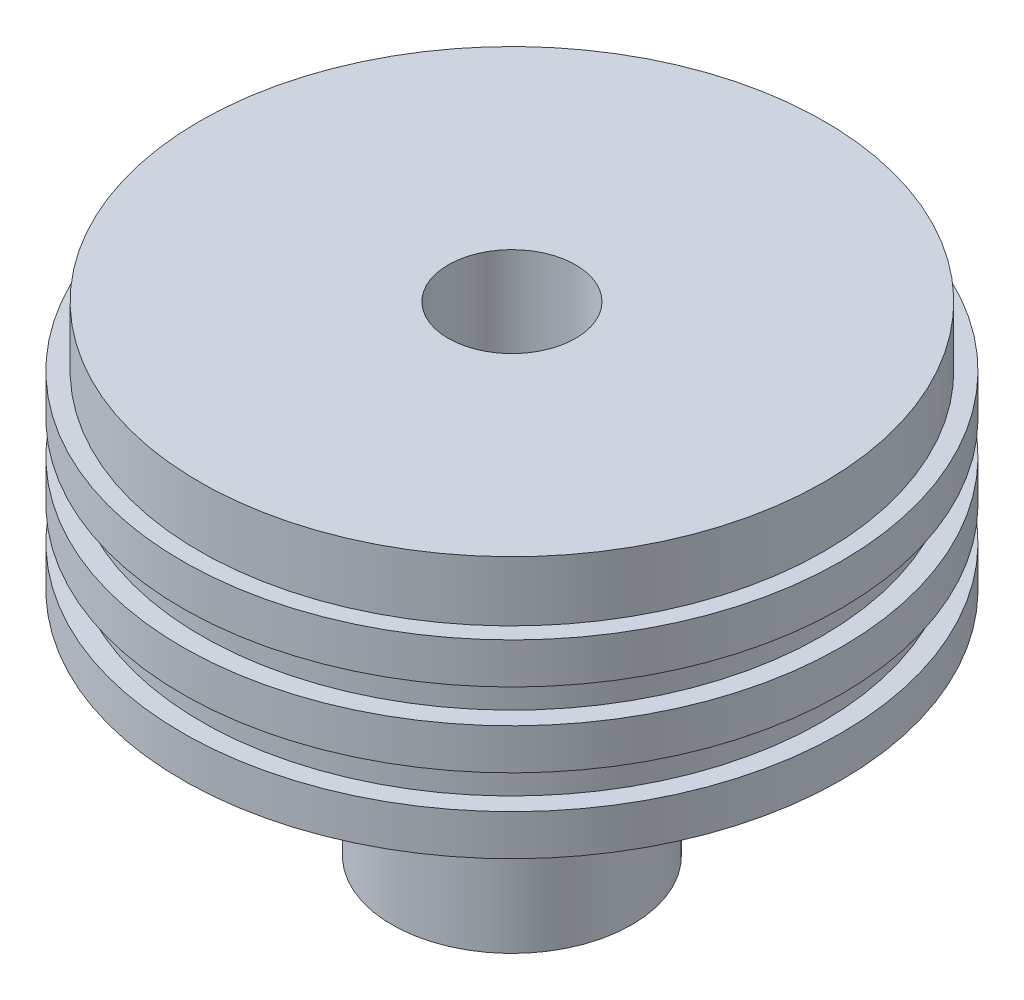
from build123d import *

# Parameters (mm, degrees)
F_5_8_11_TAPPED_HOLE1_D = 13.49248


with BuildPart() as part:
    # Sketch8 → Revolve1 (revolve)
    with BuildSketch(Plane.XY):
        Polygon((0, 0), (0, 26.416), (-33.0835, 26.416), (-33.0835, 20.066), (-34.8996, 20.066), (-34.8996, 15.748), (-32.8676, 15.748), (-32.8676, 12.192), (-34.8996, 12.192), (-34.8996, 7.874), (-32.8676, 7.874), (-32.8676, 4.318), (-34.8996, 4.318), (-34.8996, 0), (-12.7, 0), (-12.7, -24.384), (0, -24.384), align=None)
    revolve(axis=Axis((0, 0, 0), (0, 1, 0)))

    # 5/8-11 Tapped Hole1 (through all)
    with Locations(Plane(origin=(0, 26.416, 0), x_dir=(1, 0, 0), z_dir=(0, 1, 0))):
        with Locations((0, 0)):
            Hole(F_5_8_11_TAPPED_HOLE1_D / 2)


solid = part.part
